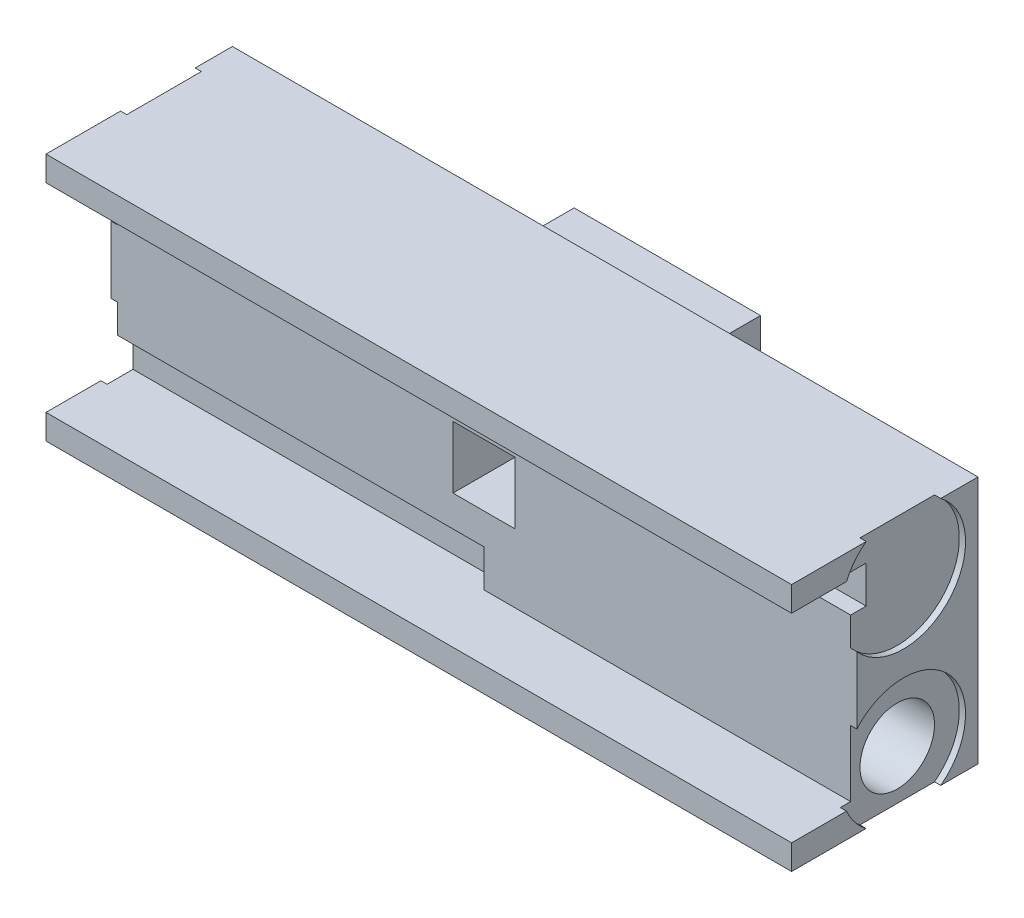
from build123d import *

# Parameters (mm, degrees)
SKETCH1_W           = 120
SKETCH1_H           = 40
BOSS_EXTRUDE1_DEPTH = 30
CUT_EXTRUDE1_DEPTH  = 60
CUT_EXTRUDE2_DEPTH  = 60
SKETCH6_W           = 30
SKETCH6_H           = 30
BOSS_EXTRUDE2_DEPTH = 10
SKETCH7_R           = 10
CUT_EXTRUDE3_DEPTH  = 1
SKETCH9_R           = 6
CUT_EXTRUDE4_DEPTH  = 35
SKETCH10_R          = 6
CUT_EXTRUDE5_DEPTH  = 35
SKETCH11_W          = 10
SKETCH11_H          = 10
CUT_EXTRUDE6_DEPTH  = 10


with BuildPart() as part:
    # Sketch1 → Boss-Extrude1 (new body)
    with BuildSketch(Plane.XY):
        with Locations((354.047582571, 83.912277662)):
            Rectangle(SKETCH1_W, SKETCH1_H)
    extrude(amount=BOSS_EXTRUDE1_DEPTH)

    # Sketch2 → Cut-Extrude1 (cut)
    with BuildSketch(Plane(origin=(414.047582571, 0, 0), x_dir=(0, 0, -1), z_dir=(1, 0, 0))):
        Polygon((-30, 99.912277662), (-19.5, 99.912277662), (-17, 99.912277662), (-17, 93.912277662), (-19.5, 93.912277662), (-19.5, 67.912277662), (-30, 67.912277662), align=None)
    extrude(amount=-CUT_EXTRUDE1_DEPTH, mode=Mode.SUBTRACT)

    # Sketch5 → Cut-Extrude2 (cut)
    with BuildSketch(Plane.ZY.offset(-294.047582571)):
        Polygon((30, 99.912277662), (19.5, 99.912277662), (19.5, 73.912277662), (17, 73.912277662), (17, 67.912277662), (19.5, 67.912277662), (30, 67.912277662), align=None)
    extrude(amount=-CUT_EXTRUDE2_DEPTH, mode=Mode.SUBTRACT)

    # Sketch6 → Boss-Extrude2 (add)
    with BuildSketch(Plane(origin=(0, 0, 0), x_dir=(-1, 0, 0), z_dir=(0, 0, -1))):
        with Locations((-354.047582571, 83.912277662)):
            Rectangle(SKETCH6_W, SKETCH6_H)
    extrude(amount=BOSS_EXTRUDE2_DEPTH)

    # Sketch7 → Cut-Extrude3 (cut)
    with BuildSketch(Plane(origin=(414.047582571, 0, 0), x_dir=(0, 0, -1), z_dir=(1, 0, 0))):
        with Locations((-12, 95.912277662)):
            Circle(SKETCH7_R)
        with Locations((-12, 71.912277662)):
            Circle(SKETCH7_R)
    cut_extrude3 = extrude(amount=-CUT_EXTRUDE3_DEPTH, mode=Mode.SUBTRACT)

    # Mirror1: Cut-Extrude3 across plane
    add(cut_extrude3.mirror(Plane.ZY.offset(-354.047582571)), mode=Mode.SUBTRACT)

    # Sketch9 → Cut-Extrude4 (cut)
    with BuildSketch(Plane(origin=(413.047582571, 0, 0), x_dir=(0, 0, -1), z_dir=(1, 0, 0))):
        with Locations((-12, 71.912277662)):
            Circle(SKETCH9_R)
    extrude(amount=-CUT_EXTRUDE4_DEPTH, mode=Mode.SUBTRACT)

    # Sketch10 → Cut-Extrude5 (cut)
    with BuildSketch(Plane.ZY.offset(-295.047582571)):
        with Locations((12, 95.912277662)):
            Circle(SKETCH10_R)
    extrude(amount=-CUT_EXTRUDE5_DEPTH, mode=Mode.SUBTRACT)

    # Sketch11 → Cut-Extrude6 (cut)
    with BuildSketch(Plane.XY.offset(19.5)):
        with Locations((354.047582571, 83.912277662)):
            Rectangle(SKETCH11_W, SKETCH11_H)
    extrude(amount=-CUT_EXTRUDE6_DEPTH, mode=Mode.SUBTRACT)


solid = part.part
